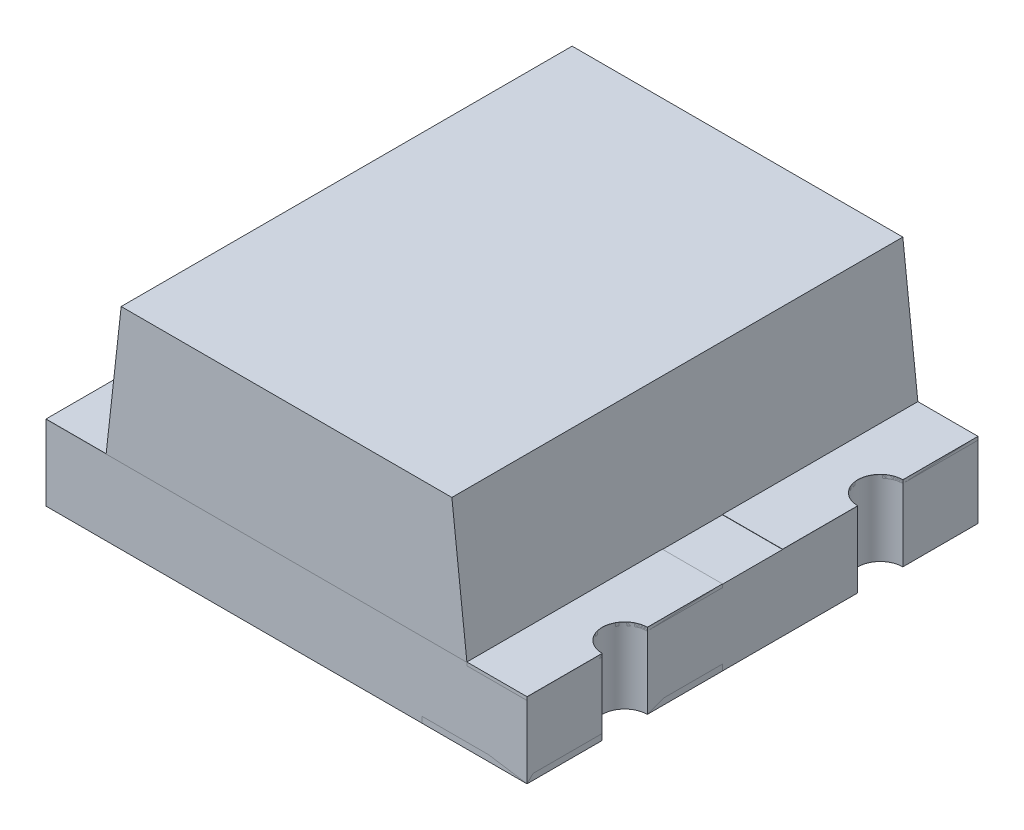
from build123d import *

# Parameters (mm, degrees)
SKETCH1_W             = 1.6
SKETCH1_H             = 0.25
EXTRUDE1_DEPTH        = 0.75
EXTRUDE2_DEPTH        = 0.75
EXTRUDE3_DEPTH        = 0.0001
EXTRUDE3_DEPTH_BACK   = 0.02
EXTRUDE3_2_DEPTH      = 0.0001
EXTRUDE3_2_DEPTH_BACK = 0.02
EXTRUDE3_3_DEPTH      = 0.0001
EXTRUDE3_3_DEPTH_BACK = 0.02
EXTRUDE3_4_DEPTH      = 0.0001
EXTRUDE3_4_DEPTH_BACK = 0.02
SKETCH2_3_W           = 0.279958711
SKETCH2_3_H           = 0.727414088
EXTRUDE4_DEPTH        = 0.0001
EXTRUDE4_DEPTH_BACK   = 0.01
CUT_EXTRUDE2_DEPTH    = 1.7
EXTRUDE5_DEPTH        = 0.001
EXTRUDE5_DEPTH_BACK   = 0.01
EXTRUDE5_2_DEPTH      = 0.001
EXTRUDE5_2_DEPTH_BACK = 0.01
EXTRUDE5_3_DEPTH      = 0.001
EXTRUDE5_3_DEPTH_BACK = 0.01
EXTRUDE5_4_DEPTH      = 0.001
EXTRUDE5_4_DEPTH_BACK = 0.01
SKETCH5_W             = 0.026582278
SKETCH5_H             = 0.025316456
CUT_EXTRUDE3_DEPTH    = 0.01


with BuildPart() as part:
    # Sketch1 → Extrude1 (new body, symmetric)
    with BuildSketch(Plane.XY):
        Rectangle(SKETCH1_W, SKETCH1_H)
    extrude(amount=EXTRUDE1_DEPTH, both=True)

    # Sketch2_4 → Cut-Extrude2 (cut, through all)
    with BuildSketch(Plane.XZ.offset(0.125)):
        with BuildLine():
            ThreePointArc((-0.8, 0.35), (-0.725, 0.425), (-0.8, 0.5))
            Line((-0.8, 0.5), (-0.8, 0.35))
        make_face()
        with BuildLine():
            Line((-0.8, -0.35), (-0.8, -0.5))
            ThreePointArc((-0.8, -0.5), (-0.725, -0.425), (-0.8, -0.35))
        make_face()
        with BuildLine():
            ThreePointArc((0.8, -0.35), (0.725, -0.425), (0.8, -0.5))
            Line((0.8, -0.5), (0.8, -0.35))
        make_face()
        with BuildLine():
            Line((0.8, 0.35), (0.8, 0.5))
            ThreePointArc((0.8, 0.5), (0.725, 0.425), (0.8, 0.35))
        make_face()
    extrude(amount=-CUT_EXTRUDE2_DEPTH, mode=Mode.SUBTRACT)

    # Sketch5 → Cut-Extrude3 (cut)
    with BuildSketch(Plane.XZ.offset(0.125)):
        Polygon((-0.337264638, 0.572151899), (-0.411948182, 0.595609177), (-0.411948182, 0.620352057), (-0.361611948, 0.636768196), (-0.411948182, 0.652294304), (-0.411948182, 0.678026108), (-0.337264638, 0.701265823), (-0.337264638, 0.676087816), (-0.388748024, 0.663093354), (-0.337264638, 0.646677215), (-0.337264638, 0.625178006), (-0.388748024, 0.608860759), (-0.337264638, 0.596044304), align=None)
        Polygon((-0.337264638, 0.437974684), (-0.411948182, 0.461431962), (-0.411948182, 0.486174842), (-0.361611948, 0.502590981), (-0.411948182, 0.518117089), (-0.411948182, 0.543848892), (-0.337264638, 0.567088608), (-0.337264638, 0.541910601), (-0.388748024, 0.528916139), (-0.337264638, 0.5125), (-0.337264638, 0.491000791), (-0.388748024, 0.474683544), (-0.337264638, 0.461867089), align=None)
        Polygon((-0.337264638, 0.303797468), (-0.411948182, 0.327254747), (-0.411948182, 0.351997627), (-0.361611948, 0.368413766), (-0.411948182, 0.383939873), (-0.411948182, 0.409671677), (-0.337264638, 0.432911392), (-0.337264638, 0.407733386), (-0.388748024, 0.394738924), (-0.337264638, 0.378322785), (-0.337264638, 0.356823576), (-0.388748024, 0.340506329), (-0.337264638, 0.327689873), align=None)
        with Locations((-0.398657043, 0.275949367)):
            Rectangle(SKETCH5_W, SKETCH5_H)
        with BuildLine():
            add(Edge.make_bspline(
                [(-0.380777296, 0.159493671), (-0.38199943, 0.159530169), (-0.384399293, 0.15960184), (-0.387906981, 0.160211426), (-0.391231284, 0.161205393), (-0.39439543, 0.162577732), (-0.397364919, 0.164371189), (-0.40016781, 0.16655446), (-0.402772354, 0.169143343), (-0.405208729, 0.172090146), (-0.40739084, 0.175387089), (-0.409296874, 0.178984804), (-0.410891545, 0.18286483), (-0.41223061, 0.187013042), (-0.413219043, 0.191459588), (-0.413943031, 0.196177087), (-0.414416349, 0.201170514), (-0.414458317, 0.204594091), (-0.414479828, 0.206348892)],
                knots=[0, 0, 0, 0, 0.907312236, 1.78165839, 2.635367075, 3.479697475, 4.336364812, 5.205276731, 6.11257575, 7.058770404, 8.040786331, 9.044147278, 10.078219212, 11.153049307, 12.278104542, 13.457648573, 14.696882856, 16, 16, 16, 16], degree=3))
            add(Edge.make_bspline(
                [(-0.414479828, 0.206348892), (-0.414455756, 0.208367148), (-0.414409132, 0.21227633), (-0.413980533, 0.217939855), (-0.413334393, 0.223207892), (-0.412367851, 0.228103607), (-0.411167086, 0.232708206), (-0.409875795, 0.237141474), (-0.408411379, 0.241422786), (-0.407311221, 0.244195876), (-0.40676622, 0.24556962)],
                knots=[0, 0, 0, 0, 1.203215828, 2.33052265, 3.384689099, 4.366106119, 5.303329643, 6.221311756, 7.118865988, 8, 8, 8, 8], degree=3))
            Line((-0.40676622, 0.24556962), (-0.382834258, 0.24556962))
            Line((-0.382834258, 0.24556962), (-0.382834258, 0.242721519))
            add(Edge.make_bspline(
                [(-0.382834258, 0.242721519), (-0.383915713, 0.241356205), (-0.386072274, 0.238633592), (-0.388834879, 0.234200359), (-0.391237042, 0.229552713), (-0.393211044, 0.224707243), (-0.394797368, 0.219810398), (-0.395890896, 0.21493502), (-0.396638245, 0.210169433), (-0.396718751, 0.207010864), (-0.396758309, 0.205458861)],
                knots=[0, 0, 0, 0, 1.030622468, 2.055194264, 3.087043286, 4.125157485, 5.149848264, 6.130935704, 7.081611712, 8, 8, 8, 8], degree=3))
            add(Edge.make_bspline(
                [(-0.396758309, 0.205458861), (-0.396757415, 0.205030082), (-0.3967555, 0.2041121), (-0.396626657, 0.202644063), (-0.396533493, 0.200985464), (-0.396324276, 0.199206598), (-0.396105692, 0.197415781), (-0.395725372, 0.195761121), (-0.395363533, 0.194257482), (-0.394995356, 0.193351), (-0.394820018, 0.192919304)],
                knots=[0, 0, 0, 0, 0.806378557, 1.726393851, 2.771014456, 3.931269413, 5.096090628, 6.161710732, 7.124547685, 8, 8, 8, 8], degree=3))
            add(Edge.make_bspline(
                [(-0.394820018, 0.192919304), (-0.394592194, 0.192439517), (-0.394144472, 0.191496634), (-0.393326865, 0.190201714), (-0.392455563, 0.189019042), (-0.391490145, 0.187957582), (-0.390312236, 0.187107314), (-0.38891138, 0.186479113), (-0.387261079, 0.186136019), (-0.386086069, 0.186096725), (-0.385464796, 0.186075949)],
                knots=[0, 0, 0, 0, 1.024407818, 2.013179384, 2.949802342, 3.859052226, 4.77034807, 5.732977883, 6.801339628, 8, 8, 8, 8], degree=3))
            add(Edge.make_bspline(
                [(-0.385464796, 0.186075949), (-0.3849189, 0.186107391), (-0.383845508, 0.186169215), (-0.382317511, 0.186751006), (-0.380895635, 0.187633905), (-0.379634919, 0.188920927), (-0.378477481, 0.190515003), (-0.377507184, 0.19247074), (-0.37662711, 0.194723719), (-0.376209842, 0.196368178), (-0.375990904, 0.197231013)],
                knots=[0, 0, 0, 0, 0.825212765, 1.622611382, 2.449701629, 3.348069183, 4.336544339, 5.428209675, 6.6506027, 8, 8, 8, 8], degree=3))
            add(Edge.make_bspline(
                [(-0.375990904, 0.197231013), (-0.375543163, 0.19919974), (-0.374625973, 0.203232648), (-0.373478866, 0.209380757), (-0.372212793, 0.215510984), (-0.371003252, 0.219469696), (-0.370413372, 0.221400316)],
                knots=[0, 0, 0, 0, 0.976104583, 1.999535498, 3.024395274, 4, 4, 4, 4], degree=3))
            add(Edge.make_bspline(
                [(-0.370413372, 0.221400316), (-0.37006038, 0.222438832), (-0.369373247, 0.224460401), (-0.368211622, 0.227351945), (-0.36694167, 0.230013057), (-0.365586538, 0.232453168), (-0.36411254, 0.23465249), (-0.362579151, 0.236647679), (-0.360925313, 0.238391205), (-0.359193394, 0.239938889), (-0.357341391, 0.241262203), (-0.355397255, 0.242416954), (-0.353336789, 0.243392589), (-0.351175501, 0.244201473), (-0.348896632, 0.244818545), (-0.346519759, 0.245239801), (-0.344036398, 0.24553819), (-0.342342045, 0.245559001), (-0.341477455, 0.24556962)],
                knots=[0, 0, 0, 0, 1.287286806, 2.505824366, 3.654938963, 4.74627059, 5.778586806, 6.75996495, 7.696030012, 8.595059759, 9.482019644, 10.363222407, 11.245851011, 12.154256429, 13.068444161, 14.012503255, 14.985824751, 16, 16, 16, 16], degree=3))
            add(Edge.make_bspline(
                [(-0.341477455, 0.24556962), (-0.34032131, 0.245532318), (-0.338046038, 0.245458909), (-0.334716993, 0.24485748), (-0.331568257, 0.24383089), (-0.328564794, 0.242444827), (-0.325751708, 0.240616199), (-0.32307316, 0.238431404), (-0.320601569, 0.235807357), (-0.318301235, 0.232830235), (-0.316221837, 0.229542851), (-0.31439128, 0.226003867), (-0.312854629, 0.222234578), (-0.311580735, 0.218249032), (-0.310626064, 0.214030563), (-0.309907132, 0.20959333), (-0.30949395, 0.204919541), (-0.3094427, 0.20172812), (-0.309416537, 0.200098892)],
                knots=[0, 0, 0, 0, 0.894990994, 1.761326291, 2.609044902, 3.454222546, 4.315366365, 5.200560057, 6.125081389, 7.100429509, 8.110379559, 9.133447974, 10.182136699, 11.259192205, 12.370181258, 13.528580438, 14.738335141, 16, 16, 16, 16], degree=3))
            add(Edge.make_bspline(
                [(-0.309416537, 0.200098892), (-0.309438728, 0.198430205), (-0.309483074, 0.19509566), (-0.309861051, 0.190114218), (-0.31041628, 0.185153716), (-0.311257985, 0.180289886), (-0.312234402, 0.175599331), (-0.313330198, 0.171186095), (-0.314568162, 0.167106634), (-0.315522507, 0.16453297), (-0.315982993, 0.163291139)],
                knots=[0, 0, 0, 0, 1.065403572, 2.129000689, 3.188532477, 4.251604565, 5.279552602, 6.247508681, 7.154397237, 8, 8, 8, 8], degree=3))
            Line((-0.315982993, 0.163291139), (-0.338530461, 0.163291139))
            Line((-0.338530461, 0.163291139), (-0.338530461, 0.166119462))
            add(Edge.make_bspline(
                [(-0.338530461, 0.166119462), (-0.337730114, 0.167192367), (-0.336093384, 0.169386485), (-0.334009712, 0.173046122), (-0.332051846, 0.177004358), (-0.330367688, 0.181283188), (-0.328908206, 0.185742216), (-0.32788904, 0.190325174), (-0.327247231, 0.194951338), (-0.327174456, 0.198053049), (-0.327138056, 0.19960443)],
                knots=[0, 0, 0, 0, 0.892283326, 1.824742884, 2.804416662, 3.836872171, 4.8899239, 5.931447339, 6.965372909, 8, 8, 8, 8], degree=3))
            add(Edge.make_bspline(
                [(-0.327138056, 0.19960443), (-0.327159508, 0.200700098), (-0.32720241, 0.202891315), (-0.327593095, 0.206159523), (-0.328223988, 0.209401584), (-0.32904327, 0.211442107), (-0.329452138, 0.212460443)],
                knots=[0, 0, 0, 0, 0.999146175, 1.998183711, 3.000980573, 4, 4, 4, 4], degree=3))
            add(Edge.make_bspline(
                [(-0.329452138, 0.212460443), (-0.329653605, 0.212893946), (-0.330056404, 0.213760664), (-0.330828968, 0.214967308), (-0.331757779, 0.216071977), (-0.332809771, 0.217064055), (-0.333966145, 0.217932452), (-0.335240971, 0.218547803), (-0.336603885, 0.218923676), (-0.337539116, 0.218965835), (-0.33801622, 0.218987342)],
                knots=[0, 0, 0, 0, 1.00524851, 2.009826503, 3.004679593, 4.035271301, 5.048246368, 6.034938417, 6.997532266, 8, 8, 8, 8], degree=3))
            add(Edge.make_bspline(
                [(-0.33801622, 0.218987342), (-0.338654386, 0.218952904), (-0.339873861, 0.218887095), (-0.341589657, 0.218280511), (-0.343068091, 0.217295678), (-0.344063011, 0.216135073), (-0.344760449, 0.215017943), (-0.34527096, 0.213982284), (-0.345754319, 0.212773057), (-0.346251787, 0.211401809), (-0.346742975, 0.209865482), (-0.347218521, 0.208156925), (-0.347667817, 0.206274208), (-0.347954008, 0.204958333), (-0.348103246, 0.204272152)],
                knots=[0, 0, 0, 0, 1.173816843, 2.243057204, 3.312297565, 4.415174738, 5.03266065, 5.73970059, 6.541434878, 7.433956553, 8.430083051, 9.515931566, 10.70464786, 12, 12, 12, 12], degree=3))
            add(Edge.make_bspline(
                [(-0.348103246, 0.204272152), (-0.348479307, 0.202439363), (-0.349218185, 0.198838337), (-0.350321673, 0.193437153), (-0.351596643, 0.18793438), (-0.352745446, 0.184269053), (-0.353344543, 0.182357595)],
                knots=[0, 0, 0, 0, 0.995744513, 1.956417928, 2.934277412, 4, 4, 4, 4], degree=3))
            add(Edge.make_bspline(
                [(-0.353344543, 0.182357595), (-0.353663787, 0.181411041), (-0.35428828, 0.179559428), (-0.355374562, 0.176918797), (-0.356548545, 0.174471738), (-0.357790077, 0.172204706), (-0.359134043, 0.170130736), (-0.36055669, 0.168236053), (-0.362083599, 0.166552235), (-0.363696826, 0.16505467), (-0.365406927, 0.16373551), (-0.367245999, 0.162603212), (-0.369194801, 0.161630984), (-0.371281001, 0.160861379), (-0.373475588, 0.160243358), (-0.375806956, 0.159820261), (-0.378251333, 0.159526278), (-0.37992591, 0.159504661), (-0.380777296, 0.159493671)],
                knots=[0, 0, 0, 0, 1.237467875, 2.420686895, 3.535046182, 4.599015201, 5.620884487, 6.594603852, 7.531477383, 8.433220087, 9.318759595, 10.202828513, 11.105163009, 12.01247538, 12.953896178, 13.926381251, 14.945733412, 16, 16, 16, 16], degree=3))
        make_face()
        with BuildLine():
            Line((-0.411948182, 0.067088608), (-0.411948182, 0.091139241))
            Line((-0.411948182, 0.091139241), (-0.404115904, 0.091139241))
            add(Edge.make_bspline(
                [(-0.404115904, 0.091139241), (-0.404924462, 0.092232549), (-0.406483351, 0.094340433), (-0.408563568, 0.097513458), (-0.410338835, 0.100539548), (-0.411898055, 0.103453039), (-0.413073441, 0.106475242), (-0.413901507, 0.109706756), (-0.414401279, 0.113209581), (-0.414453063, 0.115636475), (-0.414479828, 0.116890823)],
                knots=[0, 0, 0, 0, 1.150872466, 2.218865267, 3.209461834, 4.120482262, 5.012764827, 5.946708227, 6.938749913, 8, 8, 8, 8], degree=3))
            add(Edge.make_bspline(
                [(-0.414479828, 0.116890823), (-0.414457109, 0.117907175), (-0.414412869, 0.119886305), (-0.414067991, 0.122763545), (-0.413530339, 0.125471173), (-0.412722748, 0.127986213), (-0.411756945, 0.130350202), (-0.410476987, 0.132487752), (-0.409046813, 0.134491354), (-0.407339767, 0.136273026), (-0.405442034, 0.137888648), (-0.403309574, 0.139271198), (-0.400976649, 0.140448909), (-0.398424795, 0.141390006), (-0.395666491, 0.142145096), (-0.392687244, 0.142669028), (-0.389500116, 0.142989621), (-0.387304986, 0.14302156), (-0.386176822, 0.143037975)],
                knots=[0, 0, 0, 0, 1.109008058, 2.159558935, 3.158726032, 4.116861086, 5.039058877, 5.938775559, 6.82970133, 7.720510853, 8.624361809, 9.544451588, 10.487360536, 11.471068125, 12.508000841, 13.604731202, 14.768976642, 16, 16, 16, 16], degree=3))
            Line((-0.386176822, 0.143037975), (-0.337264638, 0.143037975))
            Line((-0.337264638, 0.143037975), (-0.337264638, 0.118987342))
            Line((-0.337264638, 0.118987342), (-0.374843752, 0.118987342))
            add(Edge.make_bspline(
                [(-0.374843752, 0.118987342), (-0.375760223, 0.118985706), (-0.377514439, 0.118982576), (-0.380020245, 0.118900237), (-0.382288418, 0.118779336), (-0.384330446, 0.118640631), (-0.386177197, 0.118387615), (-0.387843358, 0.118009906), (-0.38936296, 0.11753908), (-0.390269662, 0.117074761), (-0.390706094, 0.116851266)],
                knots=[0, 0, 0, 0, 1.361401701, 2.605856924, 3.723918663, 4.735739235, 5.645738665, 6.489217889, 7.27279937, 8, 8, 8, 8], degree=3))
            add(Edge.make_bspline(
                [(-0.390706094, 0.116851266), (-0.391104809, 0.116621259), (-0.391888648, 0.116169086), (-0.392894826, 0.115248796), (-0.393739094, 0.114170053), (-0.394395122, 0.112892449), (-0.394894071, 0.111405901), (-0.395234308, 0.109677971), (-0.395449809, 0.107692609), (-0.395477718, 0.106283591), (-0.395492486, 0.105537975)],
                knots=[0, 0, 0, 0, 0.849138082, 1.669332372, 2.503455908, 3.370611167, 4.311442699, 5.394692208, 6.621337967, 8, 8, 8, 8], degree=3))
            add(Edge.make_bspline(
                [(-0.395492486, 0.105537975), (-0.395475129, 0.104996691), (-0.395439442, 0.103883773), (-0.395206996, 0.102172461), (-0.394850321, 0.100375884), (-0.394190466, 0.097861301), (-0.393004286, 0.094694674), (-0.391649879, 0.092335372), (-0.390963214, 0.091139241)],
                knots=[0, 0, 0, 0, 0.638127216, 1.312033637, 2.033062677, 2.79661882, 4.375931797, 6, 6, 6, 6], degree=3))
            Line((-0.390963214, 0.091139241), (-0.337264638, 0.091139241))
            Line((-0.337264638, 0.091139241), (-0.337264638, 0.067088608))
            Line((-0.337264638, 0.067088608), (-0.411948182, 0.067088608))
        make_face()
        with BuildLine():
            Line((-0.411948182, -0.030379747), (-0.411948182, -0.006329114))
            Line((-0.411948182, -0.006329114), (-0.374369069, -0.006329114))
            add(Edge.make_bspline(
                [(-0.374369069, -0.006329114), (-0.372839026, -0.0063046), (-0.369788001, -0.006255716), (-0.36602559, -0.005973592), (-0.363183265, -0.00559507), (-0.361345384, -0.005225415), (-0.359797245, -0.004793715), (-0.358911486, -0.004381435), (-0.358506727, -0.004193038)],
                knots=[0, 0, 0, 0, 1.709124929, 3.408128882, 4.211124727, 4.91016634, 5.501986363, 6, 6, 6, 6], degree=3))
            add(Edge.make_bspline(
                [(-0.358506727, -0.004193038), (-0.358108673, -0.003948575), (-0.357328234, -0.003469272), (-0.35631522, -0.002531948), (-0.35548638, -0.001438061), (-0.354804829, -0.000167292), (-0.354334248, 0.001323905), (-0.353941018, 0.003040645), (-0.35377411, 0.005027263), (-0.353738949, 0.006434533), (-0.353720334, 0.007179589)],
                knots=[0, 0, 0, 0, 0.86006424, 1.686277094, 2.52783008, 3.38194165, 4.331801563, 5.402842185, 6.624978739, 8, 8, 8, 8], degree=3))
            add(Edge.make_bspline(
                [(-0.353720334, 0.007179589), (-0.353777072, 0.00831141), (-0.353892925, 0.010622505), (-0.354604433, 0.013484698), (-0.355423392, 0.015815302), (-0.356182222, 0.017667827), (-0.357153664, 0.019576457), (-0.357875487, 0.020855869), (-0.358249607, 0.021518987)],
                knots=[0, 0, 0, 0, 1.338371478, 2.732853438, 3.468019217, 4.261884641, 5.099136535, 6, 6, 6, 6], degree=3))
            Line((-0.358249607, 0.021518987), (-0.411948182, 0.021518987))
            Line((-0.411948182, 0.021518987), (-0.411948182, 0.04556962))
            Line((-0.411948182, 0.04556962), (-0.337264638, 0.04556962))
            Line((-0.337264638, 0.04556962), (-0.337264638, 0.021518987))
            Line((-0.337264638, 0.021518987), (-0.345096917, 0.021518987))
            add(Edge.make_bspline(
                [(-0.345096917, 0.021518987), (-0.344290765, 0.020461581), (-0.342721543, 0.018403276), (-0.340681122, 0.015224038), (-0.338882353, 0.01214014), (-0.337369537, 0.009087131), (-0.336162762, 0.005972176), (-0.335351773, 0.002709417), (-0.33480797, -0.000706989), (-0.334758276, -0.003043704), (-0.334732993, -0.004232595)],
                knots=[0, 0, 0, 0, 1.126119141, 2.192057864, 3.198061997, 4.149848529, 5.076251285, 6.021887753, 6.99356175, 8, 8, 8, 8], degree=3))
            add(Edge.make_bspline(
                [(-0.334732993, -0.004232595), (-0.334758382, -0.005228866), (-0.334807945, -0.007173765), (-0.335117655, -0.010008526), (-0.335668319, -0.012679947), (-0.336466149, -0.015172221), (-0.337451761, -0.017514841), (-0.338683276, -0.019676785), (-0.340141699, -0.021668856), (-0.341802701, -0.023497257), (-0.343692428, -0.025128075), (-0.345809692, -0.026545111), (-0.348152789, -0.027725092), (-0.350713098, -0.028695805), (-0.353478207, -0.029470228), (-0.356474172, -0.029985359), (-0.359678351, -0.030339143), (-0.361894394, -0.030365941), (-0.363035999, -0.030379747)],
                knots=[0, 0, 0, 0, 1.08848837, 2.124922927, 3.110950502, 4.063144162, 4.979605775, 5.882838355, 6.774625441, 7.671951181, 8.57587277, 9.494821853, 10.448322275, 11.435533005, 12.482327682, 13.580118324, 14.753386918, 16, 16, 16, 16], degree=3))
            Line((-0.363035999, -0.030379747), (-0.411948182, -0.030379747))
        make_face()
        Polygon((-0.411948182, -0.125316456), (-0.411948182, -0.053164557), (-0.311948182, -0.053164557), (-0.311948182, -0.078481013), (-0.392960841, -0.078481013), (-0.392960841, -0.125316456), align=None)
        Polygon((-0.411948182, -0.212658228), (-0.411948182, -0.140506329), (-0.311948182, -0.140506329), (-0.311948182, -0.212658228), (-0.330935524, -0.212658228), (-0.330935524, -0.165822785), (-0.348657043, -0.165822785), (-0.348657043, -0.208860759), (-0.367644385, -0.208860759), (-0.367644385, -0.165822785), (-0.392960841, -0.165822785), (-0.392960841, -0.212658228), align=None)
        with BuildLine():
            add(Edge.make_bspline(
                [(-0.362047075, -0.329113924), (-0.363194764, -0.329094609), (-0.36546765, -0.329056357), (-0.368832456, -0.328761165), (-0.372098132, -0.32823514), (-0.37528238, -0.327555959), (-0.378361308, -0.326633453), (-0.381368885, -0.325551739), (-0.384274379, -0.324242093), (-0.387075813, -0.322737241), (-0.389747916, -0.321087768), (-0.392268125, -0.319313019), (-0.394651343, -0.31746724), (-0.396846237, -0.315477927), (-0.398888256, -0.313398746), (-0.40077907, -0.311223217), (-0.402482501, -0.308918153), (-0.403505385, -0.30731099), (-0.404017012, -0.30650712)],
                knots=[0, 0, 0, 0, 1.105570398, 2.18947457, 3.250358341, 4.290584537, 5.323553275, 6.344225964, 7.367641686, 8.3905646, 9.405808457, 10.390761353, 11.358902336, 12.307789878, 13.241960776, 14.165076779, 15.082208636, 16, 16, 16, 16], degree=3))
            add(Edge.make_bspline(
                [(-0.404017012, -0.30650712), (-0.404729151, -0.305267892), (-0.406157063, -0.302783112), (-0.407825654, -0.298799278), (-0.40922977, -0.294673795), (-0.410284195, -0.290323409), (-0.411011239, -0.285676399), (-0.411572045, -0.28067499), (-0.411873805, -0.275267401), (-0.411922825, -0.271532506), (-0.411948182, -0.269600475)],
                knots=[0, 0, 0, 0, 0.896288622, 1.797150563, 2.705281913, 3.629615989, 4.602417572, 5.655716007, 6.787320449, 8, 8, 8, 8], degree=3))
            Line((-0.411948182, -0.269600475), (-0.411948182, -0.234177215))
            Line((-0.411948182, -0.234177215), (-0.311948182, -0.234177215))
            Line((-0.311948182, -0.234177215), (-0.311948182, -0.270609177))
            add(Edge.make_bspline(
                [(-0.311948182, -0.270609177), (-0.311964793, -0.272587909), (-0.311996834, -0.276404637), (-0.312414425, -0.281921476), (-0.313011249, -0.287026684), (-0.313936119, -0.291712032), (-0.315051465, -0.296012037), (-0.316410593, -0.299937513), (-0.317909301, -0.303549287), (-0.319182994, -0.305728129), (-0.319800239, -0.306784019)],
                knots=[0, 0, 0, 0, 1.267175336, 2.444223962, 3.542125549, 4.557526608, 5.500936977, 6.385043188, 7.217374394, 8, 8, 8, 8], degree=3))
            add(Edge.make_bspline(
                [(-0.319800239, -0.306784019), (-0.32033678, -0.307634972), (-0.321403694, -0.309327097), (-0.323185546, -0.311728312), (-0.325141623, -0.313957739), (-0.327193442, -0.316086242), (-0.329396328, -0.318066059), (-0.331735036, -0.319909259), (-0.33421313, -0.321613076), (-0.336822599, -0.323171039), (-0.339552651, -0.324591854), (-0.34242571, -0.32578116), (-0.34540424, -0.326830509), (-0.348513202, -0.327636046), (-0.351721038, -0.32833396), (-0.355062382, -0.328768694), (-0.358514871, -0.329055305), (-0.36085976, -0.32909422), (-0.362047075, -0.329113924)],
                knots=[0, 0, 0, 0, 0.964065863, 1.917049184, 2.86229036, 3.805247319, 4.749389377, 5.698846072, 6.657678277, 7.629829384, 8.610569287, 9.604676042, 10.607940105, 11.6349849, 12.681042988, 13.752616828, 14.862056989, 16, 16, 16, 16], degree=3))
        make_face()
        with BuildLine():
            add(Edge.make_bspline(
                [(-0.361888847, -0.302531646), (-0.361084087, -0.302521405), (-0.359505503, -0.302501317), (-0.357189988, -0.30230975), (-0.354960339, -0.302050694), (-0.352825646, -0.30161964), (-0.350766076, -0.301119993), (-0.348808582, -0.300477843), (-0.346929008, -0.299753447), (-0.34515152, -0.298871809), (-0.343443137, -0.297898172), (-0.341857622, -0.296750679), (-0.340344736, -0.295502341), (-0.338916751, -0.294124054), (-0.337610855, -0.292581114), (-0.336380779, -0.290921012), (-0.335252453, -0.289120654), (-0.334592403, -0.287847665), (-0.334258309, -0.287203323)],
                knots=[0, 0, 0, 0, 1.152093354, 2.259898929, 3.325467225, 4.364140538, 5.376172865, 6.358396836, 7.312077728, 8.257828931, 9.196960457, 10.124297759, 11.056236784, 12.004246951, 12.961658638, 13.947279359, 14.960983522, 16, 16, 16, 16], degree=3))
            add(Edge.make_bspline(
                [(-0.334258309, -0.287203323), (-0.333951597, -0.286528425), (-0.333343672, -0.285190731), (-0.33261248, -0.283119908), (-0.332039644, -0.281030524), (-0.331608786, -0.278828925), (-0.331286855, -0.276359165), (-0.331089597, -0.273433583), (-0.330947428, -0.269977674), (-0.330939676, -0.267490959), (-0.330935524, -0.266159019)],
                knots=[0, 0, 0, 0, 0.826967603, 1.639107464, 2.447640171, 3.242670507, 4.14065217, 5.225198036, 6.513753944, 8, 8, 8, 8], degree=3))
            Line((-0.330935524, -0.266159019), (-0.330935524, -0.259493671))
            Line((-0.330935524, -0.259493671), (-0.392960841, -0.259493671))
            Line((-0.392960841, -0.259493671), (-0.392960841, -0.266159019))
            add(Edge.make_bspline(
                [(-0.392960841, -0.266159019), (-0.392956091, -0.266917226), (-0.392946921, -0.268380991), (-0.392903859, -0.270497235), (-0.392856972, -0.272463031), (-0.39274051, -0.274267902), (-0.392667864, -0.275926587), (-0.392489485, -0.277413368), (-0.392347305, -0.278755857), (-0.392079582, -0.280323454), (-0.391663399, -0.28217662), (-0.39098522, -0.28433788), (-0.390134824, -0.286478414), (-0.389449857, -0.287866987), (-0.389104037, -0.288568038)],
                knots=[0, 0, 0, 0, 1.186793418, 2.291178421, 3.313283093, 4.264083014, 5.122158624, 5.910777728, 6.607099052, 7.234812932, 8.398911528, 9.577194775, 10.776795607, 12, 12, 12, 12], degree=3))
            add(Edge.make_bspline(
                [(-0.389104037, -0.288568038), (-0.388762521, -0.289153154), (-0.388089006, -0.29030708), (-0.386954932, -0.291930584), (-0.385747208, -0.293438302), (-0.384458757, -0.294834314), (-0.383070515, -0.296097614), (-0.381603974, -0.297249633), (-0.380055995, -0.298280082), (-0.377862477, -0.299515471), (-0.374831541, -0.300738716), (-0.370864155, -0.301778259), (-0.366504391, -0.30241513), (-0.363466774, -0.302491812), (-0.361888847, -0.302531646)],
                knots=[0, 0, 0, 0, 0.755160452, 1.489275589, 2.205657296, 2.907868421, 3.605098304, 4.296256403, 4.985378686, 5.676536785, 7.100390329, 8.614249252, 10.241231541, 12, 12, 12, 12], degree=3))
        make_face(mode=Mode.SUBTRACT)
        with Locations((-0.398657043, -0.360759494)):
            Rectangle(SKETCH5_W, SKETCH5_H)
        with BuildLine():
            add(Edge.make_bspline(
                [(-0.414479828, -0.435403481), (-0.414458017, -0.433813368), (-0.414415205, -0.430692232), (-0.413938288, -0.42612089), (-0.413220593, -0.421755717), (-0.412199686, -0.417609409), (-0.41085219, -0.413695618), (-0.409199255, -0.41003198), (-0.40721407, -0.406625123), (-0.405634861, -0.404566476), (-0.404847708, -0.403540348)],
                knots=[0, 0, 0, 0, 1.123670284, 2.205584497, 3.245308791, 4.249063313, 5.220352711, 6.167273909, 7.086481357, 8, 8, 8, 8], degree=3))
            add(Edge.make_bspline(
                [(-0.404847708, -0.403540348), (-0.403992934, -0.402588601), (-0.402286691, -0.400688786), (-0.399315264, -0.398222853), (-0.39603222, -0.396099767), (-0.392429997, -0.394314215), (-0.388513268, -0.392883291), (-0.384268606, -0.391860157), (-0.379707826, -0.391240912), (-0.376559892, -0.391173746), (-0.374942644, -0.391139241)],
                knots=[0, 0, 0, 0, 0.916457077, 1.82937027, 2.759194969, 3.714948755, 4.706655623, 5.743329475, 6.840637961, 8, 8, 8, 8], degree=3))
            add(Edge.make_bspline(
                [(-0.374942644, -0.391139241), (-0.373239417, -0.391178001), (-0.369938337, -0.391253124), (-0.36516615, -0.391916883), (-0.360748469, -0.392986496), (-0.356696561, -0.394524054), (-0.353003369, -0.396454496), (-0.349631535, -0.398718989), (-0.34658861, -0.401339514), (-0.344843171, -0.403346653), (-0.343969543, -0.404351266)],
                knots=[0, 0, 0, 0, 1.171797512, 2.271099083, 3.308930235, 4.294129479, 5.24602549, 6.17106565, 7.084581485, 8, 8, 8, 8], degree=3))
            add(Edge.make_bspline(
                [(-0.343969543, -0.404351266), (-0.343200957, -0.405377136), (-0.341654501, -0.407441268), (-0.339753801, -0.410844773), (-0.338159015, -0.414467988), (-0.336911371, -0.418297559), (-0.335957465, -0.422270367), (-0.335233622, -0.426330027), (-0.334813063, -0.43047628), (-0.334759811, -0.43326648), (-0.334732993, -0.434671677)],
                knots=[0, 0, 0, 0, 0.952130878, 1.915761808, 2.890227217, 3.891541892, 4.905612075, 5.925811839, 6.955400088, 8, 8, 8, 8], degree=3))
            add(Edge.make_bspline(
                [(-0.334732993, -0.434671677), (-0.334749995, -0.435918396), (-0.334783427, -0.438369867), (-0.335105536, -0.441970914), (-0.335638655, -0.445425455), (-0.336377258, -0.448730387), (-0.337268861, -0.451904334), (-0.338308003, -0.454954511), (-0.33944127, -0.457914321), (-0.340325805, -0.45981489), (-0.340765429, -0.460759494)],
                knots=[0, 0, 0, 0, 1.107648782, 2.178012834, 3.209595929, 4.211695017, 5.185427128, 6.137685403, 7.07440854, 8, 8, 8, 8], degree=3))
            Line((-0.340765429, -0.460759494), (-0.361315271, -0.460759494))
            Line((-0.361315271, -0.460759494), (-0.361315271, -0.45741693))
            add(Edge.make_bspline(
                [(-0.361315271, -0.45741693), (-0.360898051, -0.456917386), (-0.359996337, -0.45583775), (-0.358575585, -0.454051335), (-0.357045991, -0.451902393), (-0.356154045, -0.450248857), (-0.355678404, -0.449367089)],
                knots=[0, 0, 0, 0, 0.792826818, 1.713491785, 2.780691913, 4, 4, 4, 4], degree=3))
            add(Edge.make_bspline(
                [(-0.355678404, -0.449367089), (-0.355236446, -0.448439154), (-0.354330586, -0.446537209), (-0.353497752, -0.443981204), (-0.352930026, -0.441789202), (-0.352673605, -0.439971666), (-0.352484043, -0.438038046), (-0.352464536, -0.436702803), (-0.352454512, -0.436016614)],
                knots=[0, 0, 0, 0, 1.332524827, 2.731214173, 3.480270227, 4.267952375, 5.109889624, 6, 6, 6, 6], degree=3))
            add(Edge.make_bspline(
                [(-0.352454512, -0.436016614), (-0.352474061, -0.435251058), (-0.352511947, -0.433767448), (-0.352789003, -0.431605939), (-0.353267261, -0.429587528), (-0.353907361, -0.427684306), (-0.354794975, -0.425946243), (-0.355828612, -0.424319403), (-0.357054413, -0.422827143), (-0.358495356, -0.421507882), (-0.360075284, -0.420315156), (-0.3618094, -0.419295954), (-0.363655999, -0.418383498), (-0.365660448, -0.41768856), (-0.367789224, -0.417128822), (-0.370052344, -0.416739892), (-0.372451854, -0.416497934), (-0.374098162, -0.416470016), (-0.374942644, -0.416455696)],
                knots=[0, 0, 0, 0, 1.087302107, 2.107140881, 3.088415001, 4.030197574, 4.951552271, 5.852940509, 6.764198256, 7.685219758, 8.621679636, 9.570836121, 10.538340132, 11.542450476, 12.578202196, 13.66207107, 14.800746211, 16, 16, 16, 16], degree=3))
            add(Edge.make_bspline(
                [(-0.374942644, -0.416455696), (-0.375806801, -0.416470471), (-0.377485813, -0.416499177), (-0.379927424, -0.416732691), (-0.382208856, -0.417148582), (-0.384334176, -0.41771983), (-0.386300194, -0.418444178), (-0.38809759, -0.419349295), (-0.389754398, -0.420385652), (-0.39121701, -0.42163021), (-0.392533331, -0.422994093), (-0.393669466, -0.424508985), (-0.394617611, -0.426168224), (-0.395422074, -0.427950405), (-0.396000472, -0.429883445), (-0.396437164, -0.431939982), (-0.39672572, -0.434129537), (-0.396747283, -0.435639891), (-0.396758309, -0.436412184)],
                knots=[0, 0, 0, 0, 1.230336593, 2.390482092, 3.487897344, 4.52859895, 5.520747884, 6.465347575, 7.38981449, 8.296085817, 9.192433006, 10.084246191, 10.984321635, 11.908883871, 12.862027947, 13.850751296, 14.901019963, 16, 16, 16, 16], degree=3))
            add(Edge.make_bspline(
                [(-0.396758309, -0.436412184), (-0.396750182, -0.437138038), (-0.396734337, -0.438553063), (-0.39651626, -0.44061781), (-0.396240378, -0.442578718), (-0.39580097, -0.444414258), (-0.395258595, -0.446109524), (-0.394692088, -0.447669947), (-0.394087304, -0.449082395), (-0.39361975, -0.449943749), (-0.393395967, -0.450356013)],
                knots=[0, 0, 0, 0, 1.200823684, 2.340960236, 3.433630075, 4.476504061, 5.46014544, 6.378484521, 7.223905657, 8, 8, 8, 8], degree=3))
            add(Edge.make_bspline(
                [(-0.393395967, -0.450356013), (-0.392966073, -0.451056218), (-0.392134431, -0.452410785), (-0.390732865, -0.454249513), (-0.389318605, -0.455894382), (-0.388362387, -0.456918894), (-0.38789755, -0.45741693)],
                knots=[0, 0, 0, 0, 1.098601379, 2.125273733, 3.088655601, 4, 4, 4, 4], degree=3))
            Line((-0.38789755, -0.45741693), (-0.38789755, -0.460759494))
            Line((-0.38789755, -0.460759494), (-0.408605619, -0.460759494))
            add(Edge.make_bspline(
                [(-0.408605619, -0.460759494), (-0.409043113, -0.459814104), (-0.409918207, -0.457923097), (-0.411072079, -0.455008518), (-0.412040239, -0.452020545), (-0.41294332, -0.448972172), (-0.413631682, -0.445800089), (-0.414124805, -0.442477058), (-0.414425717, -0.43899556), (-0.414461545, -0.436617171), (-0.414479828, -0.435403481)],
                knots=[0, 0, 0, 0, 0.952012952, 1.904254716, 2.862729541, 3.822037426, 4.808956931, 5.82647221, 6.890850784, 8, 8, 8, 8], degree=3))
        make_face()
        with BuildLine():
            add(Edge.make_bspline(
                [(-0.374645967, -0.553164557), (-0.376150873, -0.553139862), (-0.379084339, -0.553091723), (-0.38335613, -0.552552407), (-0.387392128, -0.551739627), (-0.391179336, -0.550567096), (-0.394736611, -0.549086703), (-0.398026404, -0.547235764), (-0.401079633, -0.545064759), (-0.403869518, -0.542573722), (-0.406368029, -0.53977252), (-0.408563282, -0.536698338), (-0.410376723, -0.533324511), (-0.411888814, -0.5297102), (-0.413058049, -0.525825548), (-0.413870766, -0.521671329), (-0.414406237, -0.517254195), (-0.414454888, -0.514215776), (-0.414479828, -0.512658228)],
                knots=[0, 0, 0, 0, 1.120167703, 2.183507516, 3.201345984, 4.182878364, 5.131270247, 6.065524964, 6.98789854, 7.91635504, 8.84481154, 9.778033504, 10.722808862, 11.691211189, 12.691525459, 13.738229926, 14.840575679, 16, 16, 16, 16], degree=3))
            add(Edge.make_bspline(
                [(-0.414479828, -0.512658228), (-0.414454806, -0.511100707), (-0.414405994, -0.508062341), (-0.413871662, -0.503644832), (-0.413053712, -0.499485737), (-0.411897611, -0.49559643), (-0.410371061, -0.491987684), (-0.408564013, -0.488617817), (-0.40636782, -0.485544052), (-0.403869628, -0.482742566), (-0.401079402, -0.480252248), (-0.398027219, -0.478078657), (-0.394731265, -0.476236243), (-0.391188219, -0.474718389), (-0.387387382, -0.473585065), (-0.38335694, -0.472761602), (-0.37908412, -0.472225394), (-0.376150799, -0.472176819), (-0.374645967, -0.472151899)],
                knots=[0, 0, 0, 0, 1.15937715, 2.261678054, 3.308339936, 4.313313916, 5.277148057, 6.221884977, 7.155068972, 8.083487698, 9.011906424, 9.934242473, 10.868459181, 11.818729666, 12.798784262, 13.81658132, 14.879877871, 16, 16, 16, 16], degree=3))
            add(Edge.make_bspline(
                [(-0.374645967, -0.472151899), (-0.373134544, -0.472177022), (-0.370181533, -0.472226107), (-0.36588266, -0.472761477), (-0.36182201, -0.473579494), (-0.358013697, -0.474739526), (-0.354462097, -0.476255799), (-0.351159992, -0.478096824), (-0.348113417, -0.480293292), (-0.345323666, -0.48280279), (-0.342827285, -0.485614584), (-0.340654379, -0.488708516), (-0.338817722, -0.492060435), (-0.337295888, -0.495667634), (-0.336161323, -0.49955419), (-0.335343745, -0.503691132), (-0.334805672, -0.508088526), (-0.33475766, -0.511107264), (-0.334732993, -0.512658228)],
                knots=[0, 0, 0, 0, 1.124034801, 2.196132384, 3.217834281, 4.203147447, 5.152578239, 6.085969439, 7.010345409, 7.941219594, 8.872481455, 9.802010446, 10.748267785, 11.711250247, 12.709230373, 13.754967386, 14.846549946, 16, 16, 16, 16], degree=3))
            add(Edge.make_bspline(
                [(-0.334732993, -0.512658228), (-0.334757715, -0.514228966), (-0.334805847, -0.51728713), (-0.33534205, -0.521730542), (-0.336155055, -0.525904381), (-0.337321451, -0.529803006), (-0.338832865, -0.533428756), (-0.340667523, -0.536788831), (-0.342869581, -0.539860139), (-0.345376737, -0.542647393), (-0.348182138, -0.545127634), (-0.351231761, -0.54729655), (-0.354551478, -0.549103768), (-0.358106346, -0.550585538), (-0.361900115, -0.551757711), (-0.365934221, -0.552578696), (-0.370209218, -0.553084687), (-0.373141348, -0.553137471), (-0.374645967, -0.553164557)],
                knots=[0, 0, 0, 0, 1.167358552, 2.272800965, 3.322628764, 4.326027541, 5.29287265, 6.238482395, 7.166210353, 8.096447471, 9.020151799, 9.945039072, 10.873038967, 11.824425184, 12.804379233, 13.820580988, 14.881633558, 16, 16, 16, 16], degree=3))
        make_face()
        with BuildLine():
            add(Edge.make_bspline(
                [(-0.393138847, -0.523457278), (-0.392638841, -0.523812456), (-0.391621268, -0.524535285), (-0.389920845, -0.525405537), (-0.38809905, -0.526193542), (-0.386069769, -0.526811737), (-0.383767324, -0.527291059), (-0.381113731, -0.52760245), (-0.378078219, -0.527832094), (-0.375925506, -0.527842556), (-0.374784417, -0.527848101)],
                knots=[0, 0, 0, 0, 0.764956307, 1.556776596, 2.379454426, 3.241401993, 4.200532455, 5.312591107, 6.575484591, 8, 8, 8, 8], degree=3))
            add(Edge.make_bspline(
                [(-0.374784417, -0.527848101), (-0.373709535, -0.527830412), (-0.371650179, -0.527796522), (-0.368690416, -0.527610152), (-0.366006989, -0.527261478), (-0.363589593, -0.5267636), (-0.361418905, -0.526153829), (-0.359476543, -0.525427894), (-0.357757941, -0.524589376), (-0.356752709, -0.523903909), (-0.356271758, -0.523575949)],
                knots=[0, 0, 0, 0, 1.337076348, 2.561692668, 3.686680134, 4.69989255, 5.629188848, 6.488203485, 7.276684665, 8, 8, 8, 8], degree=3))
            add(Edge.make_bspline(
                [(-0.356271758, -0.523575949), (-0.355832476, -0.523238652), (-0.354970719, -0.522576962), (-0.353888534, -0.521400911), (-0.35299024, -0.520136352), (-0.352330199, -0.51875605), (-0.351810942, -0.517310883), (-0.351464105, -0.515802557), (-0.351235984, -0.514247405), (-0.351204606, -0.513193069), (-0.351188689, -0.512658228)],
                knots=[0, 0, 0, 0, 1.058684453, 2.076859345, 3.046867319, 4.017860406, 4.996047344, 5.981941452, 6.976284511, 8, 8, 8, 8], degree=3))
            add(Edge.make_bspline(
                [(-0.351188689, -0.512658228), (-0.351199635, -0.512130296), (-0.351221046, -0.511097679), (-0.351400728, -0.509595013), (-0.351695317, -0.508184065), (-0.35211325, -0.506844191), (-0.352708733, -0.505552217), (-0.353565158, -0.504317872), (-0.354640489, -0.503101936), (-0.355491007, -0.502363688), (-0.355935524, -0.501977848)],
                knots=[0, 0, 0, 0, 1.041978199, 2.038073998, 2.982578265, 3.884042198, 4.804014415, 5.778706634, 6.839057036, 8, 8, 8, 8], degree=3))
            add(Edge.make_bspline(
                [(-0.355935524, -0.501977848), (-0.35641015, -0.501644363), (-0.357408751, -0.500942719), (-0.359113271, -0.500059744), (-0.361075191, -0.49932839), (-0.363258932, -0.49863615), (-0.365730081, -0.498117886), (-0.368483359, -0.497717147), (-0.371537786, -0.497516433), (-0.373670003, -0.497484858), (-0.374784417, -0.497468354)],
                knots=[0, 0, 0, 0, 0.706185926, 1.485796665, 2.33004681, 3.254820698, 4.274138656, 5.402098861, 6.642194297, 8, 8, 8, 8], degree=3))
            add(Edge.make_bspline(
                [(-0.374784417, -0.497468354), (-0.37578688, -0.497477501), (-0.377727993, -0.497495212), (-0.380534377, -0.497694126), (-0.38313831, -0.498022802), (-0.385528342, -0.498499446), (-0.38771324, -0.49907369), (-0.389664899, -0.499821164), (-0.391419956, -0.500644638), (-0.392447698, -0.501344976), (-0.392941062, -0.501681171)],
                knots=[0, 0, 0, 0, 1.270915159, 2.460926195, 3.565223763, 4.596447547, 5.549594966, 6.425286377, 7.244063354, 8, 8, 8, 8], degree=3))
            add(Edge.make_bspline(
                [(-0.392941062, -0.501681171), (-0.393357548, -0.502021731), (-0.394178676, -0.502693168), (-0.395262692, -0.503842086), (-0.396124042, -0.505125798), (-0.396854531, -0.506477001), (-0.397383777, -0.507938804), (-0.397760383, -0.509490696), (-0.397976137, -0.511142431), (-0.398007865, -0.512275225), (-0.398024132, -0.512856013)],
                knots=[0, 0, 0, 0, 1.011121112, 1.993489184, 2.956264801, 3.910060304, 4.874908638, 5.87009835, 6.907993364, 8, 8, 8, 8], degree=3))
            add(Edge.make_bspline(
                [(-0.398024132, -0.512856013), (-0.397970549, -0.513856962), (-0.397863627, -0.515854325), (-0.397151975, -0.518269474), (-0.396302696, -0.520076797), (-0.395423441, -0.521316068), (-0.394383902, -0.522472259), (-0.393557924, -0.523125727), (-0.393138847, -0.523457278)],
                knots=[0, 0, 0, 0, 1.48399549, 2.96126462, 3.700919455, 4.439278468, 5.208134679, 6, 6, 6, 6], degree=3))
        make_face(mode=Mode.SUBTRACT)
        with BuildLine():
            Line((-0.358249607, -0.644303797), (-0.411948182, -0.644303797))
            Line((-0.411948182, -0.644303797), (-0.411948182, -0.620253165))
            Line((-0.411948182, -0.620253165), (-0.37409217, -0.620253165))
            add(Edge.make_bspline(
                [(-0.37409217, -0.620253165), (-0.373202135, -0.620247698), (-0.371494504, -0.62023721), (-0.36903489, -0.620204186), (-0.366786286, -0.620123915), (-0.364740087, -0.620016376), (-0.362880622, -0.619829431), (-0.361205786, -0.619518092), (-0.359700261, -0.619096595), (-0.358799313, -0.618688245), (-0.358368277, -0.61849288)],
                knots=[0, 0, 0, 0, 1.339742217, 2.570446543, 3.702449567, 4.726327994, 5.654556215, 6.512888379, 7.288529137, 8, 8, 8, 8], degree=3))
            add(Edge.make_bspline(
                [(-0.358368277, -0.61849288), (-0.35798291, -0.618282954), (-0.357219017, -0.61786683), (-0.356251156, -0.616998785), (-0.355440511, -0.615990476), (-0.354799057, -0.614810314), (-0.354300894, -0.613431631), (-0.353951549, -0.611816509), (-0.353771147, -0.609952652), (-0.353737909, -0.608630364), (-0.353720334, -0.607931171)],
                knots=[0, 0, 0, 0, 0.859345536, 1.703436662, 2.532498256, 3.390183975, 4.328249457, 5.402602062, 6.626559876, 8, 8, 8, 8], degree=3))
            add(Edge.make_bspline(
                [(-0.353720334, -0.607931171), (-0.353743897, -0.607343877), (-0.353791234, -0.60616399), (-0.354032773, -0.604405516), (-0.354534718, -0.602686303), (-0.355371357, -0.600467627), (-0.356587823, -0.597858323), (-0.357709713, -0.595885907), (-0.358249607, -0.594936709)],
                knots=[0, 0, 0, 0, 0.759443456, 1.525737455, 2.286422378, 3.068189154, 4.58910569, 6, 6, 6, 6], degree=3))
            Line((-0.358249607, -0.594936709), (-0.411948182, -0.594936709))
            Line((-0.411948182, -0.594936709), (-0.411948182, -0.570886076))
            Line((-0.411948182, -0.570886076), (-0.337264638, -0.570886076))
            Line((-0.337264638, -0.570886076), (-0.337264638, -0.594936709))
            Line((-0.337264638, -0.594936709), (-0.345096917, -0.594936709))
            add(Edge.make_bspline(
                [(-0.345096917, -0.594936709), (-0.344315435, -0.595957746), (-0.342798114, -0.597940187), (-0.340752178, -0.60095416), (-0.338988743, -0.603909643), (-0.337458185, -0.606810759), (-0.336202804, -0.609757207), (-0.335366038, -0.612851706), (-0.334833719, -0.616094453), (-0.334766977, -0.618312736), (-0.334732993, -0.619442247)],
                knots=[0, 0, 0, 0, 1.136140478, 2.205924536, 3.217129804, 4.176128364, 5.103417168, 6.04061054, 7.002313223, 8, 8, 8, 8], degree=3))
            add(Edge.make_bspline(
                [(-0.334732993, -0.619442247), (-0.334764738, -0.62064549), (-0.334826782, -0.622997145), (-0.335496044, -0.626409066), (-0.336500669, -0.629624954), (-0.337991101, -0.632580961), (-0.339823902, -0.635303105), (-0.34210161, -0.637694085), (-0.344747416, -0.639808625), (-0.346759051, -0.640898753), (-0.34778679, -0.641455696)],
                knots=[0, 0, 0, 0, 1.06605855, 2.083537511, 3.073064962, 4.046068917, 5.009676085, 5.97370914, 6.964773701, 8, 8, 8, 8], degree=3))
            add(Edge.make_bspline(
                [(-0.34778679, -0.641455696), (-0.346809831, -0.642637783), (-0.344905925, -0.644941441), (-0.34236323, -0.648495035), (-0.340108929, -0.651974192), (-0.338199216, -0.655414444), (-0.336654328, -0.658810095), (-0.335548728, -0.662189222), (-0.334865281, -0.665538003), (-0.33477658, -0.667771262), (-0.334732993, -0.668868671)],
                knots=[0, 0, 0, 0, 1.188124574, 2.315425566, 3.384037189, 4.39937427, 5.362203716, 6.270239573, 7.150007311, 8, 8, 8, 8], degree=3))
            add(Edge.make_bspline(
                [(-0.334732993, -0.668868671), (-0.334756367, -0.66985193), (-0.334801848, -0.671765088), (-0.335137144, -0.67454753), (-0.335707882, -0.677144118), (-0.336502134, -0.679566684), (-0.337525551, -0.681809925), (-0.33879938, -0.68386078), (-0.340305561, -0.685715362), (-0.342005367, -0.687408252), (-0.343939713, -0.688889581), (-0.346067375, -0.690193193), (-0.348418393, -0.69124157), (-0.350946508, -0.692146787), (-0.353683785, -0.692828576), (-0.356626384, -0.693319319), (-0.359766405, -0.693617336), (-0.361927741, -0.693652735), (-0.363035999, -0.693670886)],
                knots=[0, 0, 0, 0, 1.099321551, 2.138985818, 3.128101353, 4.067593225, 4.984602876, 5.878565082, 6.75932895, 7.650734189, 8.554641537, 9.477588118, 10.434248276, 11.427530835, 12.477080043, 13.583595796, 14.760951851, 16, 16, 16, 16], degree=3))
            Line((-0.363035999, -0.693670886), (-0.411948182, -0.693670886))
            Line((-0.411948182, -0.693670886), (-0.411948182, -0.669620253))
            Line((-0.411948182, -0.669620253), (-0.37409217, -0.669620253))
            add(Edge.make_bspline(
                [(-0.37409217, -0.669620253), (-0.373195553, -0.669614543), (-0.371474758, -0.669603583), (-0.369008405, -0.669573902), (-0.366760588, -0.669484266), (-0.364720696, -0.669403721), (-0.362868563, -0.6692351), (-0.361196913, -0.668948066), (-0.359704925, -0.668517939), (-0.358800001, -0.668126047), (-0.358368277, -0.667939082)],
                knots=[0, 0, 0, 0, 1.350843832, 2.592553583, 3.715618503, 4.739861077, 5.667890227, 6.515410335, 7.291728161, 8, 8, 8, 8], degree=3))
            add(Edge.make_bspline(
                [(-0.358368277, -0.667939082), (-0.357983271, -0.667735705), (-0.357221013, -0.667333048), (-0.356246041, -0.666483931), (-0.355435433, -0.66547211), (-0.354800104, -0.66427512), (-0.35429764, -0.662871659), (-0.353956197, -0.661235308), (-0.353768734, -0.659346374), (-0.353737171, -0.658010726), (-0.353720334, -0.657298259)],
                knots=[0, 0, 0, 0, 0.846473755, 1.675897046, 2.498822796, 3.361436039, 4.304631926, 5.39613934, 6.611038701, 8, 8, 8, 8], degree=3))
            add(Edge.make_bspline(
                [(-0.353720334, -0.657298259), (-0.35376757, -0.656297285), (-0.353862588, -0.654283768), (-0.354579337, -0.651800391), (-0.35539397, -0.649778602), (-0.356173242, -0.648078656), (-0.357142568, -0.64623747), (-0.357869708, -0.644967369), (-0.358249607, -0.644303797)],
                knots=[0, 0, 0, 0, 1.291138276, 2.597198332, 3.312242316, 4.108946311, 5.012008063, 6, 6, 6, 6], degree=3))
        make_face()
    extrude(amount=-CUT_EXTRUDE3_DEPTH, mode=Mode.SUBTRACT)


with BuildPart() as body_2:
    # Sketch1_3 → Extrude2 (new body, symmetric)
    with BuildSketch(Plane.XY):
        Polygon((-0.6, 0.125), (0.6, 0.125), (0.55, 0.575), (-0.55, 0.575), align=None)
    extrude(amount=EXTRUDE2_DEPTH, both=True)


with BuildPart() as body_3:
    # Sketch2 → Extrude3 (new body, two sides)
    with BuildSketch(Plane.XZ.offset(0.125)) as extrude3_sk:
        with BuildLine():
            Line((-0.45, 0.75), (-0.8, 0.75))
            Line((-0.8, 0.75), (-0.8, 0.5))
            ThreePointArc((-0.8, 0.5), (-0.725, 0.425), (-0.8, 0.35))
            Line((-0.8, 0.35), (-0.8, 0.1))
            Line((-0.8, 0.1), (-0.45, 0.1))
            Line((-0.45, 0.1), (-0.45, 0.75))
        make_face()
    extrude(amount=EXTRUDE3_DEPTH)
    extrude(extrude3_sk.sketch, amount=-EXTRUDE3_DEPTH_BACK)


with BuildPart() as body_4:
    # Sketch2 → Extrude3 2 (new body, two sides)
    with BuildSketch(Plane.XZ.offset(0.125)) as extrude3_2_sk:
        with BuildLine():
            Line((0.8, 0.75), (0.45, 0.75))
            Line((0.45, 0.75), (0.45, 0.1))
            Line((0.45, 0.1), (0.8, 0.1))
            Line((0.8, 0.1), (0.8, 0.35))
            ThreePointArc((0.8, 0.35), (0.725, 0.425), (0.8, 0.5))
            Line((0.8, 0.5), (0.8, 0.75))
        make_face()
    extrude(amount=EXTRUDE3_2_DEPTH)
    extrude(extrude3_2_sk.sketch, amount=-EXTRUDE3_2_DEPTH_BACK)


with BuildPart() as body_5:
    # Sketch2 → Extrude3 3 (new body, two sides)
    with BuildSketch(Plane.XZ.offset(0.125)) as extrude3_3_sk:
        with BuildLine():
            Line((0.45, -0.1), (0.45, -0.75))
            Line((0.45, -0.75), (0.8, -0.75))
            Line((0.8, -0.75), (0.8, -0.5))
            ThreePointArc((0.8, -0.5), (0.725, -0.425), (0.8, -0.35))
            Line((0.8, -0.35), (0.8, -0.1))
            Line((0.8, -0.1), (0.45, -0.1))
        make_face()
    extrude(amount=EXTRUDE3_3_DEPTH)
    extrude(extrude3_3_sk.sketch, amount=-EXTRUDE3_3_DEPTH_BACK)


with BuildPart() as body_6:
    # Sketch2 → Extrude3 4 (new body, two sides)
    with BuildSketch(Plane.XZ.offset(0.125)) as extrude3_4_sk:
        with BuildLine():
            Line((-0.45, -0.1), (-0.8, -0.1))
            Line((-0.8, -0.1), (-0.8, -0.35))
            ThreePointArc((-0.8, -0.35), (-0.725, -0.425), (-0.8, -0.5))
            Line((-0.8, -0.5), (-0.8, -0.75))
            Line((-0.8, -0.75), (-0.45, -0.75))
            Line((-0.45, -0.75), (-0.45, -0.1))
        make_face()
    extrude(amount=EXTRUDE3_4_DEPTH)
    extrude(extrude3_4_sk.sketch, amount=-EXTRUDE3_4_DEPTH_BACK)


with BuildPart() as body_7:
    # Sketch2_3 → Extrude4 (new body, two sides)
    with BuildSketch(Plane.XZ.offset(0.125)) as extrude4_sk:
        with Locations((-0.139979356, 0)):
            Rectangle(SKETCH2_3_W, SKETCH2_3_H)
        Polygon((0.265601854, 0.75), (0, 0.75), (0, 0.363707044), (0, -0.363707044), (0, -0.75), (0.265601854, -0.75), align=None)
    extrude(amount=EXTRUDE4_DEPTH)
    extrude(extrude4_sk.sketch, amount=-EXTRUDE4_DEPTH_BACK)


with BuildPart() as body_8:
    # Sketch4 → Extrude5 (new body, two sides)
    with BuildSketch(Plane(origin=(0, 0.125, 0), x_dir=(-1, 0, 0), z_dir=(0, 1, 0))) as extrude5_sk:
        with BuildLine():
            Line((0.8, -0.5), (0.8, -0.75))
            Line((0.8, -0.75), (0.6, -0.75))
            Line((0.6, -0.75), (0.6, -0.1))
            Line((0.6, -0.1), (0.8, -0.1))
            Line((0.8, -0.1), (0.8, -0.35))
            ThreePointArc((0.8, -0.35), (0.725, -0.425), (0.8, -0.5))
        make_face()
    extrude(amount=EXTRUDE5_DEPTH)
    extrude(extrude5_sk.sketch, amount=-EXTRUDE5_DEPTH_BACK)


with BuildPart() as body_9:
    # Sketch4 → Extrude5 2 (new body, two sides)
    with BuildSketch(Plane(origin=(0, 0.125, 0), x_dir=(-1, 0, 0), z_dir=(0, 1, 0))) as extrude5_2_sk:
        with BuildLine():
            Line((-0.8, -0.1), (-0.8, -0.35))
            ThreePointArc((-0.8, -0.35), (-0.725, -0.425), (-0.8, -0.5))
            Line((-0.8, -0.5), (-0.8, -0.75))
            Line((-0.8, -0.75), (-0.6, -0.75))
            Line((-0.6, -0.75), (-0.6, -0.1))
            Line((-0.6, -0.1), (-0.8, -0.1))
        make_face()
    extrude(amount=EXTRUDE5_2_DEPTH)
    extrude(extrude5_2_sk.sketch, amount=-EXTRUDE5_2_DEPTH_BACK)


with BuildPart() as body_10:
    # Sketch4 → Extrude5 3 (new body, two sides)
    with BuildSketch(Plane(origin=(0, 0.125, 0), x_dir=(-1, 0, 0), z_dir=(0, 1, 0))) as extrude5_3_sk:
        with BuildLine():
            Line((-0.8, 0.5), (-0.8, 0.75))
            Line((-0.8, 0.75), (-0.6, 0.75))
            Line((-0.6, 0.75), (-0.6, 0.1))
            Line((-0.6, 0.1), (-0.8, 0.1))
            Line((-0.8, 0.1), (-0.8, 0.35))
            ThreePointArc((-0.8, 0.35), (-0.725, 0.425), (-0.8, 0.5))
        make_face()
    extrude(amount=EXTRUDE5_3_DEPTH)
    extrude(extrude5_3_sk.sketch, amount=-EXTRUDE5_3_DEPTH_BACK)


with BuildPart() as body_11:
    # Sketch4 → Extrude5 4 (new body, two sides)
    with BuildSketch(Plane(origin=(0, 0.125, 0), x_dir=(-1, 0, 0), z_dir=(0, 1, 0))) as extrude5_4_sk:
        with BuildLine():
            Line((0.8, 0.1), (0.8, 0.35))
            ThreePointArc((0.8, 0.35), (0.725, 0.425), (0.8, 0.5))
            Line((0.8, 0.5), (0.8, 0.75))
            Line((0.8, 0.75), (0.6, 0.75))
            Line((0.6, 0.75), (0.6, 0.1))
            Line((0.6, 0.1), (0.8, 0.1))
        make_face()
    extrude(amount=EXTRUDE5_4_DEPTH)
    extrude(extrude5_4_sk.sketch, amount=-EXTRUDE5_4_DEPTH_BACK)


solid = Compound([part.part, body_2.part, body_3.part, body_4.part, body_5.part, body_6.part, body_7.part, body_8.part, body_9.part, body_10.part, body_11.part])
